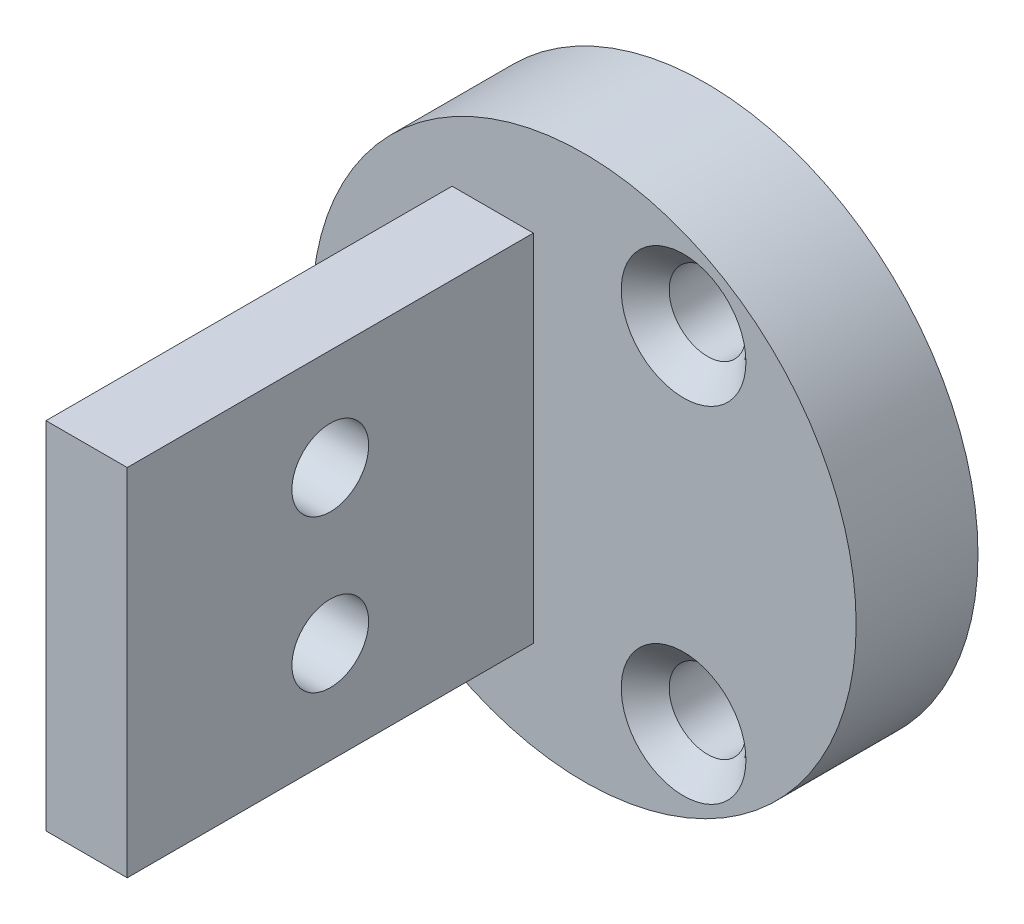
from build123d import *

# Parameters (mm, degrees)
SKETCH2_R            = 8.509
BOSS_EXTRUDE1_DEPTH  = 3.81
SKETCH4_W            = 2.54
SKETCH4_H            = 11.1125
BOSS_EXTRUDE2_DEPTH  = 12.7
M2_CLEARANCE_HOLE1_D = 2.4
M2_CLEARANCE_HOLE2_D = 2.4
CHAMFER1_SIZE        = 0.75
CHAMFER2_SIZE        = 0.75
CHAMFER3_SIZE        = 0.75


with BuildPart() as part:
    # Sketch2 → Boss-Extrude1 (new body)
    with BuildSketch(Plane.XY):
        Circle(SKETCH2_R)
    extrude(amount=BOSS_EXTRUDE1_DEPTH)

    # Sketch4 → Boss-Extrude2 (add)
    with BuildSketch(Plane.XY.offset(3.81)):
        with Locations((-2.8575, 0)):
            Rectangle(SKETCH4_W, SKETCH4_H)
    extrude(amount=BOSS_EXTRUDE2_DEPTH)

    # M2 Clearance Hole1 (through all)
    with Locations(Plane.XY.offset(3.81)):
        with Locations((-6.223, 0), (3.1115, 5.389276088), (3.1115, -5.389276088)):
            Hole(M2_CLEARANCE_HOLE1_D / 2)

    # M2 Clearance Hole2 (through all)
    with Locations(Plane(origin=(-1.5875, 0, 0), x_dir=(0, 0, -1), z_dir=(1, 0, 0))):
        with Locations((-10.16, -2.38125), (-10.16, 2.38125)):
            Hole(M2_CLEARANCE_HOLE2_D / 2)

    # Chamfer1
    chamfer1_edges = [part.edges().sort_by_distance(p)[0] for p in [
        (4.3115, -5.389276088, 3.81),
    ]]
    chamfer(chamfer1_edges, length=CHAMFER1_SIZE)

    # Chamfer2
    chamfer2_edges = [part.edges().sort_by_distance(p)[0] for p in [
        (4.3115, 5.389276088, 3.81),
    ]]
    chamfer(chamfer2_edges, length=CHAMFER2_SIZE)

    # Chamfer3
    chamfer3_edges = [part.edges().sort_by_distance(p)[0] for p in [
        (-5.023, 0, 3.81),
    ]]
    chamfer(chamfer3_edges, length=CHAMFER3_SIZE)


solid = part.part
